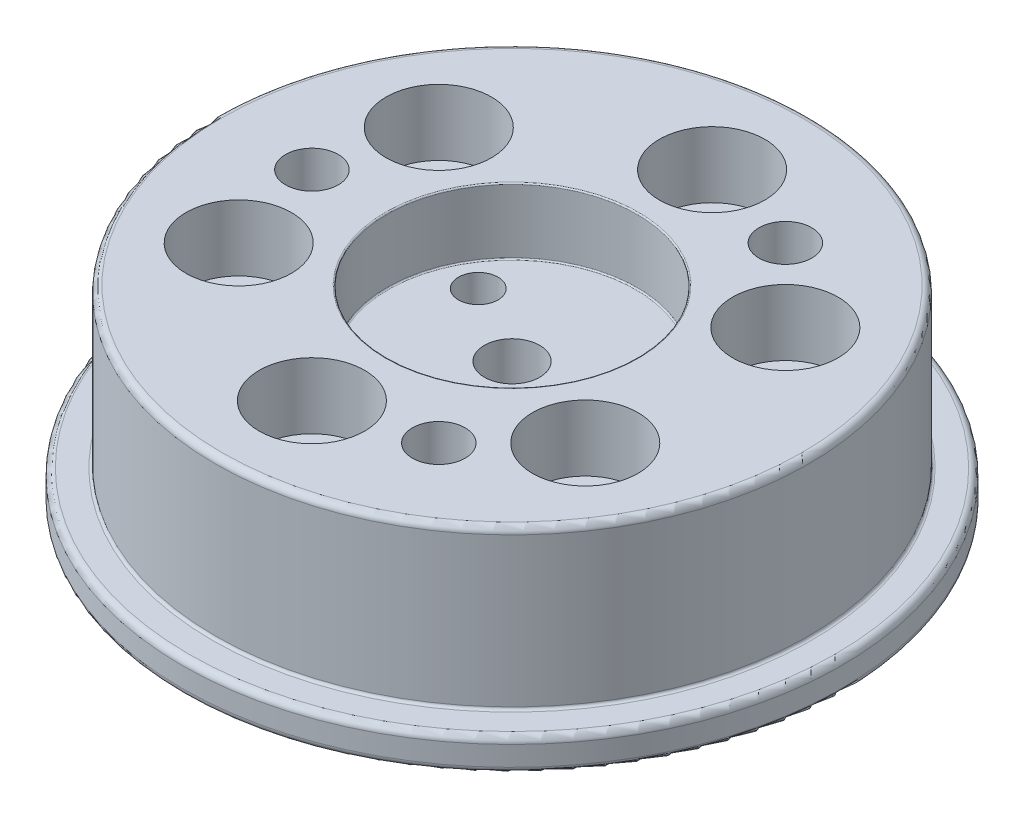
from build123d import *

# Parameters (mm, degrees)
SKETCH_1_R                   = 10.1
EXTRUDE_1_DEPTH              = 2.5
SKETCH_2_R                   = 25
EXTRUDE_2_DEPTH              = 2.5
SKETCH_3_R                   = 22.5
EXTRUDE_4_DEPTH              = 12
HOLE_WIZARD_M4_1_D           = 4.5
HOLE_WIZARD_M4_1_CBORE_D     = 8
HOLE_WIZARD_M4_1_CBORE_DEPTH = 5
PATTERN_CIRCULAR_1_COUNT     = 6
FILLET_1_R                   = 0.5
FILLET_2_R                   = 0.2
F_4_0MM_1_D                  = 4
PATTERN_CIRCULAR_3_COUNT     = 3
SKETCH_18_R                  = 9.5
CUT_EXTRUDE_1_DEPTH          = 5
FILLET_5_R                   = 0.1
PATTERN_CIRCULAR_5_COUNT     = 3
HOLE_WIZARD_M5_1_D           = 4.2


with BuildPart() as part:
    # 스케치1 → 보스-돌출1 (new body)
    with BuildSketch(Plane(origin=(0, 0, 0), x_dir=(1, 0, 0), z_dir=(0, 1, 0))):
        Circle(SKETCH_1_R)
    extrude(amount=EXTRUDE_1_DEPTH)

    # 스케치2 → 보스-돌출2 (add)
    with BuildSketch(Plane(origin=(0, 2.5, 0), x_dir=(1, 0, 0), z_dir=(0, 1, 0))):
        Circle(SKETCH_2_R)
    extrude(amount=EXTRUDE_2_DEPTH)

    # 스케치3 → 보스-돌출4 (add)
    with BuildSketch(Plane(origin=(0, 5, 0), x_dir=(1, 0, 0), z_dir=(0, 1, 0))):
        Circle(SKETCH_3_R)
    extrude(amount=EXTRUDE_4_DEPTH)

    # Hole Wizard M4 _ _ _ _ _ _1 (through all)
    with Locations(Plane(origin=(0, 17, 0), x_dir=(1, 0, 0), z_dir=(0, 1, 0))):
        with Locations((0, 15.18)):
            hole_wizard_m4_1 = CounterBoreHole(HOLE_WIZARD_M4_1_D / 2, HOLE_WIZARD_M4_1_CBORE_D / 2, HOLE_WIZARD_M4_1_CBORE_DEPTH)

    # 원형 패턴1: Hole Wizard M4 _ _ _ _ _ _1 ×6 about axis
    pattern_circular_1_axis = Axis((0, 0, 0), (0, 1, 0))
    for i in range(1, PATTERN_CIRCULAR_1_COUNT):
        add(hole_wizard_m4_1.rotate(pattern_circular_1_axis, i * 360 / PATTERN_CIRCULAR_1_COUNT), mode=Mode.SUBTRACT)

    # 필렛1
    fillet_1_edges = [part.edges().sort_by_distance(p)[0] for p in [
        (-22.5, 17, 0),
        (-10.1, 0, 0),
        (-25, 2.5, 0),
        (-25, 5, 0),
    ]]
    fillet(fillet_1_edges, radius=FILLET_1_R)

    # 필렛2
    fillet_2_edges = [part.edges().sort_by_distance(p)[0] for p in [
        (-22.5, 5, 0),
    ]]
    fillet(fillet_2_edges, radius=FILLET_2_R)

    # Ø4.0mm 맞춤핀 구멍1 (through all)
    with Locations(Plane(origin=(0, 17, 0), x_dir=(1, 0, 0), z_dir=(0, 1, 0))):
        with Locations((-15.18, 0)):
            f_4_0mm_1 = Hole(F_4_0MM_1_D / 2)

    # 원형 패턴3: Ø4.0mm 맞춤핀 구멍1 ×3 about axis
    pattern_circular_3_axis = Axis((0, 0, 0), (0, 1, 0))
    for i in range(1, PATTERN_CIRCULAR_3_COUNT):
        add(f_4_0mm_1.rotate(pattern_circular_3_axis, i * 360 / PATTERN_CIRCULAR_3_COUNT), mode=Mode.SUBTRACT)

    # 스케치18 → 컷-돌출1 (cut)
    with BuildSketch(Plane(origin=(0, 17, 0), x_dir=(1, 0, 0), z_dir=(0, 1, 0))):
        Circle(SKETCH_18_R)
    extrude(amount=-CUT_EXTRUDE_1_DEPTH, mode=Mode.SUBTRACT)

    # 필렛5
    fillet_5_edges = [part.edges().sort_by_distance(p)[0] for p in [
        (-9.5, 12, 0),
        (-9.5, 17, 0),
    ]]
    fillet(fillet_5_edges, radius=FILLET_5_R)

    # 스케치26 → Ø3.0mm 맞춤핀 구멍1 (revolve, cut)
    with BuildSketch(Plane(origin=(0, 12, 7), x_dir=(0, 0, 1), z_dir=(1, 0, 0))):
        Polygon((0, 0), (0, 5.901290929), (1.5, 5), (1.5, 0), align=None)
    f_3_0mm_1 = revolve(axis=Axis((0, 18.35, 7), (0, -1, 0)), mode=Mode.SUBTRACT)

    # 원형 패턴5: Ø3.0mm 맞춤핀 구멍1 ×3 about axis
    pattern_circular_5_axis = Axis((0, 0, 0), (0, 1, 0))
    for i in range(1, PATTERN_CIRCULAR_5_COUNT):
        add(f_3_0mm_1.rotate(pattern_circular_5_axis, i * 360 / PATTERN_CIRCULAR_5_COUNT), mode=Mode.SUBTRACT)

    # M5 탭을 위한 탭 드릴1 (through all)
    with Locations(Plane(origin=(0, 12, 0), x_dir=(1, 0, 0), z_dir=(0, 1, 0))):
        with Locations((0, 0)):
            Hole(HOLE_WIZARD_M5_1_D / 2)


solid = part.part
